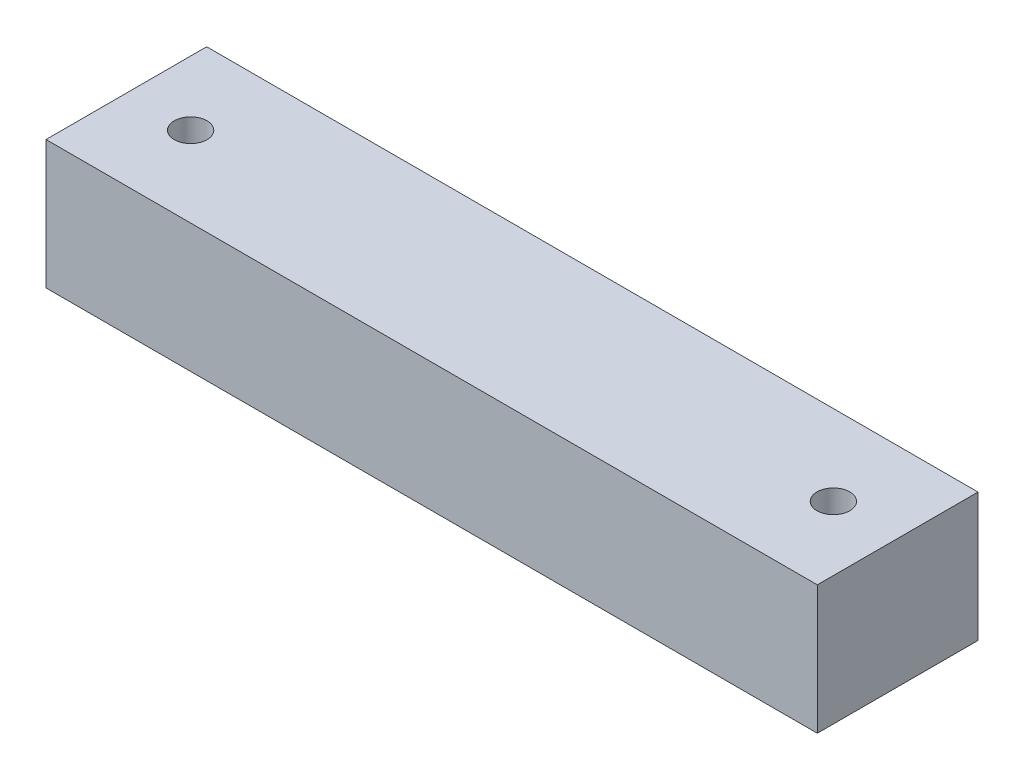
from build123d import *

# Parameters (mm, degrees)
SKETCH1_W                   = 240
SKETCH1_H                   = 50
BOSS_EXTRUDE1_DEPTH         = 40
M12X1_75_TAPPED_HOLE1_D     = 10.2
M12X1_75_TAPPED_HOLE1_DEPTH = 20
M12X1_75_TAPPED_HOLE1_TIP   = 3.064389157


with BuildPart() as part:
    # Sketch1 → Boss-Extrude1 (new body)
    with BuildSketch(Plane(origin=(0, 0, 0), x_dir=(1, 0, 0), z_dir=(0, 1, 0))):
        with Locations((120, -25)):
            Rectangle(SKETCH1_W, SKETCH1_H)
    extrude(amount=BOSS_EXTRUDE1_DEPTH)

    # M12x1.75 Tapped Hole1
    with Locations(Plane(origin=(0, 40, 0), x_dir=(1, 0, 0), z_dir=(0, 1, 0))):
        with Locations((20, -25), (220, -25)):
            Hole(M12X1_75_TAPPED_HOLE1_D / 2, depth=M12X1_75_TAPPED_HOLE1_DEPTH)
            with Locations((0, 0, -(M12X1_75_TAPPED_HOLE1_DEPTH + M12X1_75_TAPPED_HOLE1_TIP / 2))):  # 118° drill point
                Cone(0, M12X1_75_TAPPED_HOLE1_D / 2, M12X1_75_TAPPED_HOLE1_TIP, mode=Mode.SUBTRACT)


solid = part.part
